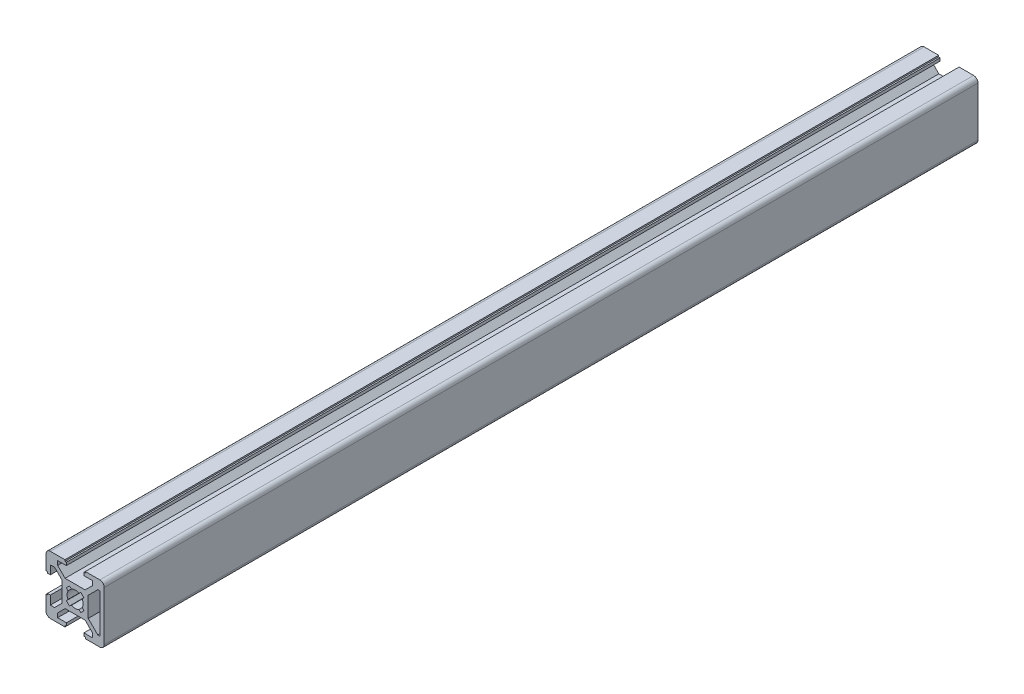
from build123d import *

# Parameters (mm, degrees)
BOSS_EXTRUDE1_DEPTH = 3000
CUT_EXTRUDE1_DEPTH  = 2700


with BuildPart() as part:
    # Sketch1 → Boss-Extrude1 (new body)
    with BuildSketch(Plane.XY):
        with BuildLine():
            Line((-3.43933983, -4.5), (3.43933983, -4.5))
            Line((3.43933983, -4.5), (6, -7.06066017))
            Line((6, -7.06066017), (6, -8.5))
            Line((6, -8.5), (3, -8.5))
            Line((3, -8.5), (3, -9.5))
            Line((3, -9.5), (3.5, -9.5))
            Line((3.5, -9.5), (3.5, -10))
            Line((3.5, -10), (8.5, -10))
            ThreePointArc((8.5, -10), (9.56066017, -9.56066017), (10, -8.5))
            Line((10, -8.5), (10, 8.5))
            ThreePointArc((10, 8.5), (9.56066017, 9.56066017), (8.5, 10))
            Line((8.5, 10), (3.5, 10))
            Line((3.5, 10), (3.5, 9.5))
            Line((3.5, 9.5), (3, 9.5))
            Line((3, 9.5), (3, 8.5))
            Line((3, 8.5), (6, 8.5))
            Line((6, 8.5), (6, 7.06066017))
            Line((6, 7.06066017), (3.43933983, 4.5))
            Line((3.43933983, 4.5), (-3.43933983, 4.5))
            Line((-3.43933983, 4.5), (-6, 7.06066017))
            Line((-6, 7.06066017), (-6, 8.5))
            Line((-6, 8.5), (-3, 8.5))
            Line((-3, 8.5), (-3, 9.5))
            Line((-3, 9.5), (-3.5, 9.5))
            Line((-3.5, 9.5), (-3.5, 10))
            Line((-3.5, 10), (-8.5, 10))
            ThreePointArc((-8.5, 10), (-9.56066017, 9.56066017), (-10, 8.5))
            Line((-10, 8.5), (-10, 3.5))
            Line((-10, 3.5), (-9.5, 3.5))
            Line((-9.5, 3.5), (-9.5, 3))
            Line((-9.5, 3), (-8.5, 3))
            Line((-8.5, 3), (-8.5, 6))
            Line((-8.5, 6), (-7.06066017, 6))
            Line((-7.06066017, 6), (-4.5, 3.43933983))
            Line((-4.5, 3.43933983), (-4.5, -3.43933983))
            Line((-4.5, -3.43933983), (-7.06066017, -6))
            Line((-7.06066017, -6), (-8.5, -6))
            Line((-8.5, -6), (-8.5, -3))
            Line((-8.5, -3), (-9.5, -3))
            Line((-9.5, -3), (-9.5, -3.5))
            Line((-9.5, -3.5), (-10, -3.5))
            Line((-10, -3.5), (-10, -8.5))
            ThreePointArc((-10, -8.5), (-9.56066017, -9.56066017), (-8.5, -10))
            Line((-8.5, -10), (-3.5, -10))
            Line((-3.5, -10), (-3.5, -9.5))
            Line((-3.5, -9.5), (-3, -9.5))
            Line((-3, -9.5), (-3, -8.5))
            Line((-3, -8.5), (-6, -8.5))
            Line((-6, -8.5), (-6, -7.06066017))
            Line((-6, -7.06066017), (-3.43933983, -4.5))
        make_face()
        Polygon((8.5, 6.73223305), (7.79289322, 6.73223305), (4.5, 3.43933983), (4.5, -3.43933983), (7.79289322, -6.73223305), (8.5, -6.73223305), align=None, mode=Mode.SUBTRACT)
        with BuildLine():
            Line((-3.0001742, 1.94957327), (-2.43563636, 1.27678327))
            ThreePointArc((-2.43563636, 1.27678327), (-2.75, 0), (-2.43563636, -1.27678327))
            Line((-2.43563636, -1.27678327), (-3.0001742, -1.94957327))
            Line((-3.0001742, -1.94957327), (-1.94957327, -3.0001742))
            Line((-1.94957327, -3.0001742), (-1.27678327, -2.43563636))
            ThreePointArc((-1.27678327, -2.43563636), (0, -2.75), (1.27678327, -2.43563636))
            Line((1.27678327, -2.43563636), (1.94957327, -3.0001742))
            Line((1.94957327, -3.0001742), (3.0001742, -1.94957327))
            Line((3.0001742, -1.94957327), (2.43563636, -1.27678327))
            ThreePointArc((2.43563636, -1.27678327), (2.75, 0), (2.43563636, 1.27678327))
            Line((2.43563636, 1.27678327), (3.0001742, 1.94957327))
            Line((3.0001742, 1.94957327), (1.94957327, 3.0001742))
            Line((1.94957327, 3.0001742), (1.27678327, 2.43563636))
            ThreePointArc((1.27678327, 2.43563636), (0, 2.75), (-1.27678327, 2.43563636))
            Line((-1.27678327, 2.43563636), (-1.94957327, 3.0001742))
            Line((-1.94957327, 3.0001742), (-3.0001742, 1.94957327))
        make_face(mode=Mode.SUBTRACT)
    extrude(amount=BOSS_EXTRUDE1_DEPTH)

    # Sketch2 → Cut-Extrude1 (cut)
    with BuildSketch(Plane.XY.offset(3000)):
        with BuildLine():
            Line((-6, -7.06066017), (-3.43933983, -4.5))
            Line((-3.43933983, -4.5), (3.43933983, -4.5))
            Line((3.43933983, -4.5), (6, -7.06066017))
            Line((6, -7.06066017), (6, -8.5))
            Line((6, -8.5), (3, -8.5))
            Line((3, -8.5), (3, -9.5))
            Line((3, -9.5), (3.5, -9.5))
            Line((3.5, -9.5), (3.5, -10))
            Line((3.5, -10), (8.5, -10))
            ThreePointArc((8.5, -10), (9.56066017, -9.56066017), (10, -8.5))
            Line((10, -8.5), (10, 8.5))
            ThreePointArc((10, 8.5), (9.56066017, 9.56066017), (8.5, 10))
            Line((8.5, 10), (3.5, 10))
            Line((3.5, 10), (3.5, 9.5))
            Line((3.5, 9.5), (3, 9.5))
            Line((3, 9.5), (3, 8.5))
            Line((3, 8.5), (6, 8.5))
            Line((6, 8.5), (6, 7.06066017))
            Line((6, 7.06066017), (3.43933983, 4.5))
            Line((3.43933983, 4.5), (-3.43933983, 4.5))
            Line((-3.43933983, 4.5), (-6, 7.06066017))
            Line((-6, 7.06066017), (-6, 8.5))
            Line((-6, 8.5), (-3, 8.5))
            Line((-3, 8.5), (-3, 9.5))
            Line((-3, 9.5), (-3.5, 9.5))
            Line((-3.5, 9.5), (-3.5, 10))
            Line((-3.5, 10), (-8.5, 10))
            ThreePointArc((-8.5, 10), (-9.56066017, 9.56066017), (-10, 8.5))
            Line((-10, 8.5), (-10, 3.5))
            Line((-10, 3.5), (-9.5, 3.5))
            Line((-9.5, 3.5), (-9.5, 3))
            Line((-9.5, 3), (-8.5, 3))
            Line((-8.5, 3), (-8.5, 6))
            Line((-8.5, 6), (-7.06066017, 6))
            Line((-7.06066017, 6), (-4.5, 3.43933983))
            Line((-4.5, 3.43933983), (-4.5, -3.43933983))
            Line((-4.5, -3.43933983), (-7.06066017, -6))
            Line((-7.06066017, -6), (-8.5, -6))
            Line((-8.5, -6), (-8.5, -3))
            Line((-8.5, -3), (-9.5, -3))
            Line((-9.5, -3), (-9.5, -3.5))
            Line((-9.5, -3.5), (-10, -3.5))
            Line((-10, -3.5), (-10, -8.5))
            ThreePointArc((-10, -8.5), (-9.56066017, -9.56066017), (-8.5, -10))
            Line((-8.5, -10), (-3.5, -10))
            Line((-3.5, -10), (-3.5, -9.5))
            Line((-3.5, -9.5), (-3, -9.5))
            Line((-3, -9.5), (-3, -8.5))
            Line((-3, -8.5), (-6, -8.5))
            Line((-6, -8.5), (-6, -7.06066017))
        make_face()
    extrude(amount=-CUT_EXTRUDE1_DEPTH, mode=Mode.SUBTRACT)


solid = part.part
